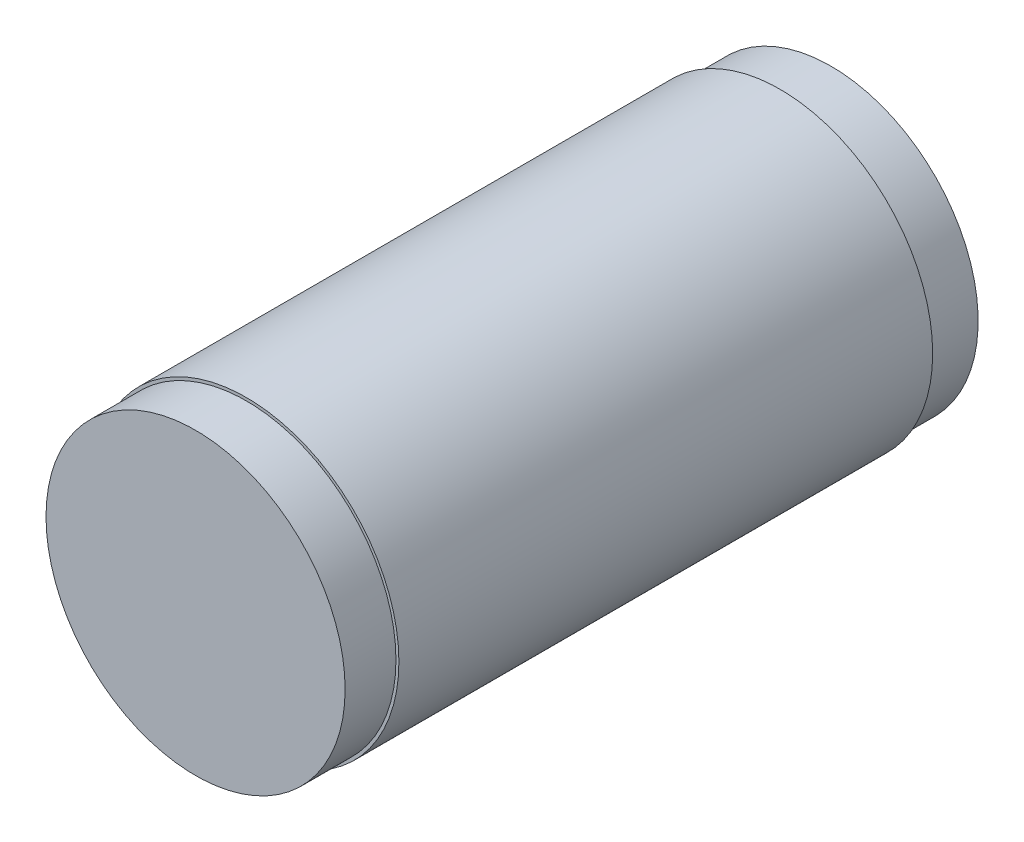
from build123d import *

# Parameters (mm, degrees)
SKETCH1_R           = 30
SKETCH1_R_2         = 25
BOSS_EXTRUDE1_DEPTH = 125
SKETCH2_R           = 25
SKETCH2_R_2         = 21.1
BOSS_EXTRUDE2_DEPTH = 10
SKETCH3_R           = 25
BOSS_EXTRUDE3_DEPTH = 10
SKETCH11_R          = 30
SKETCH11_R_2        = 28.945980101
CUT_EXTRUDE2_DEPTH  = 10
SKETCH12_R          = 30
SKETCH12_R_2        = 29.420954363
CUT_EXTRUDE3_DEPTH  = 10


with BuildPart() as part:
    # Sketch1 → Boss-Extrude1 (new body)
    with BuildSketch(Plane.XY):
        Circle(SKETCH1_R)
        Circle(SKETCH1_R_2, mode=Mode.SUBTRACT)
    extrude(amount=BOSS_EXTRUDE1_DEPTH)

    # Sketch2 → Boss-Extrude2 (add)
    with BuildSketch(Plane.XY):
        Circle(SKETCH2_R)
        Circle(SKETCH2_R_2, mode=Mode.SUBTRACT)
    extrude(amount=BOSS_EXTRUDE2_DEPTH)

    # Sketch3 → Boss-Extrude3 (add)
    with BuildSketch(Plane.XY.offset(115)):
        Circle(SKETCH3_R)
    extrude(amount=BOSS_EXTRUDE3_DEPTH)

    # Sketch11 → Cut-Extrude2 (cut)
    with BuildSketch(Plane(origin=(0, 0, 0), x_dir=(-1, 0, 0), z_dir=(0, 0, -1))):
        Circle(SKETCH11_R)
        Circle(SKETCH11_R_2, mode=Mode.SUBTRACT)
    extrude(amount=-CUT_EXTRUDE2_DEPTH, mode=Mode.SUBTRACT)

    # Sketch12 → Cut-Extrude3 (cut)
    with BuildSketch(Plane.XY.offset(125)):
        Circle(SKETCH12_R)
        Circle(SKETCH12_R_2, mode=Mode.SUBTRACT)
    extrude(amount=-CUT_EXTRUDE3_DEPTH, mode=Mode.SUBTRACT)


solid = part.part
